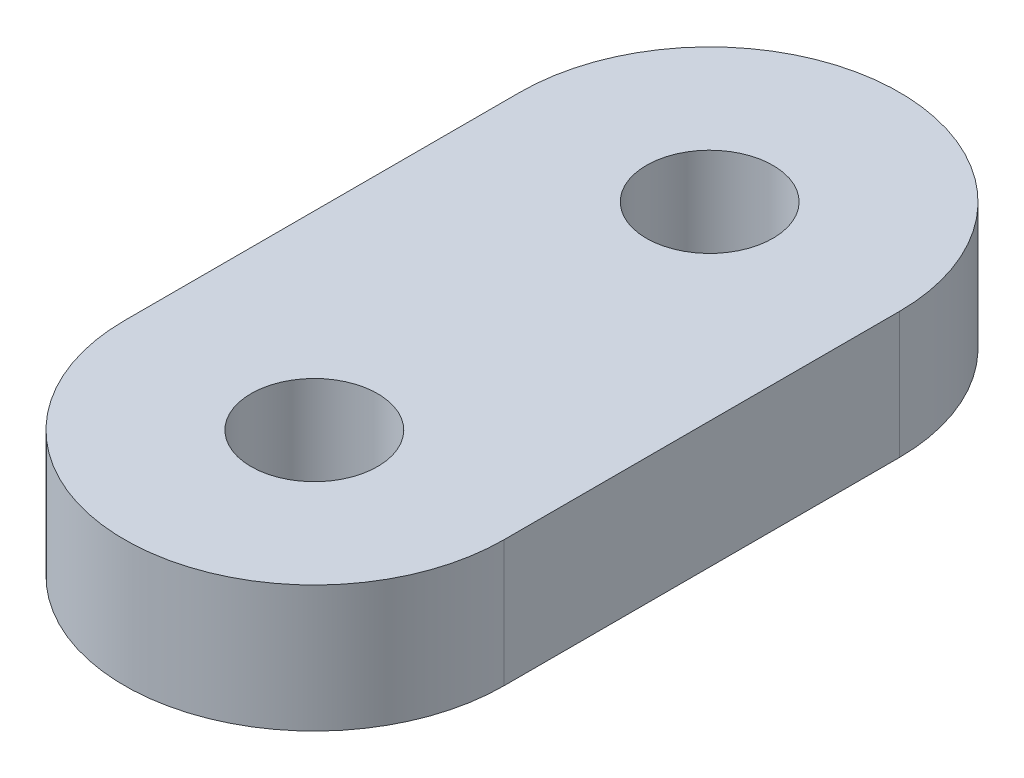
from build123d import *

# Parameters (mm, degrees)
BOSS_EXTRUDE1_DEPTH = 4
SKETCH2_R           = 2
CUT_EXTRUDE3_DEPTH  = 5


with BuildPart() as part:
    # Sketch1 → Boss-Extrude1 (new body)
    with BuildSketch(Plane(origin=(0, 0, 0), x_dir=(1, 0, 0), z_dir=(0, 1, 0))):
        with BuildLine():
            Line((6, 6.25), (6, -6.25))
            ThreePointArc((6, -6.25), (0, -12.25), (-6, -6.25))
            Line((-6, -6.25), (-6, 6.25))
            ThreePointArc((-6, 6.25), (0, 12.25), (6, 6.25))
        make_face()
    extrude(amount=BOSS_EXTRUDE1_DEPTH)

    # Sketch2 → Cut-Extrude3 (cut, through all)
    with BuildSketch(Plane(origin=(0, 4, 0), x_dir=(1, 0, 0), z_dir=(0, 1, 0))):
        with Locations((0, 6.25)):
            Circle(SKETCH2_R)
        with Locations((0, -6.25)):
            Circle(SKETCH2_R)
    extrude(amount=-CUT_EXTRUDE3_DEPTH, mode=Mode.SUBTRACT)


solid = part.part
